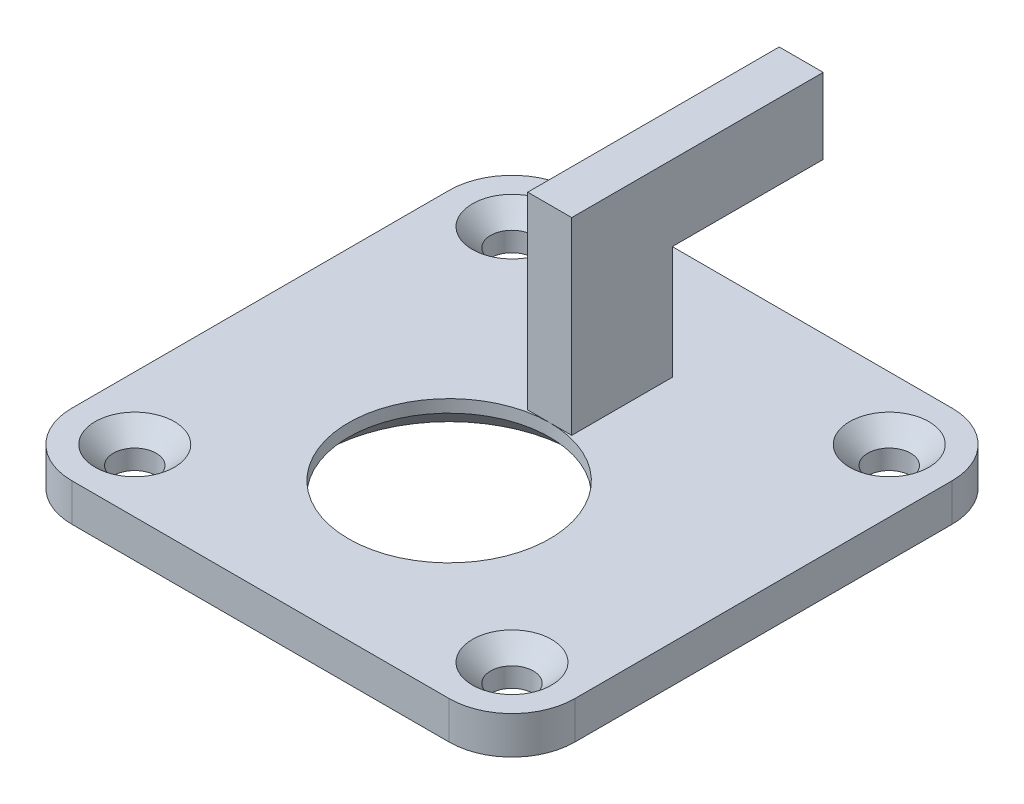
from build123d import *

# Parameters (mm, degrees)
SKETCH1_R                                    = 8
BOSS_EXTRUDE1_DEPTH                          = 3
CSK_FOR_M3_COUNTERSUNK_FLAT_HEAD_SCR_2_COUNT = 2
CSK_FOR_M3_COUNTERSUNK_FLAT_HEAD_SCR_2_PITCH = 30
CSK_FOR_M3_COUNTERSUNK_FLAT_HEAD_SCR_3_COUNT = 2
CSK_FOR_M3_COUNTERSUNK_FLAT_HEAD_SCR_3_PITCH = 42.426406871
CSK_FOR_M3_COUNTERSUNK_FLAT_HEAD_SCR_4_COUNT = 2
CSK_FOR_M3_COUNTERSUNK_FLAT_HEAD_SCR_4_PITCH = 30
CHAMFER1_SIZE                                = 2
BOSS_EXTRUDE2_DEPTH                          = 1.75


with BuildPart() as part:
    # Sketch1 → Boss-Extrude1 (new body)
    with BuildSketch(Plane(origin=(0, 0, 0), x_dir=(1, 0, 0), z_dir=(0, 1, 0))):
        with BuildLine():
            Line((-15, -15), (15, -15))
            ThreePointArc((15, -15), (18.535533906, -13.535533906), (20, -10))
            Line((20, -10), (20, 20))
            ThreePointArc((20, 20), (18.535533906, 23.535533906), (15, 25))
            Line((15, 25), (-15, 25))
            ThreePointArc((-15, 25), (-18.535533906, 23.535533906), (-20, 20))
            Line((-20, 20), (-20, -10))
            ThreePointArc((-20, -10), (-18.535533906, -13.535533906), (-15, -15))
        make_face()
        Circle(SKETCH1_R, mode=Mode.SUBTRACT)
    extrude(amount=-BOSS_EXTRUDE1_DEPTH)

    # Sketch6 → CSK for M3 Countersunk Flat Head Screw1 (revolve, cut)
    with BuildSketch(Plane(origin=(-15, 0, -20), x_dir=(0, 0, 1), z_dir=(1, 0, 0))):
        Polygon((0, 0), (0, 3), (1.7, 3), (1.7, 1.45), (3.15, 0), align=None)
    csk_for_m3_countersunk_flat_head_screw1 = revolve(axis=Axis((-15, 6.35, -20), (0, -1, 0)), mode=Mode.SUBTRACT)

    # CSK for M3 Countersunk Flat Head Scr 2: CSK for M3 Countersunk Flat Head Screw1 ×2
    with Locations(*[(i * CSK_FOR_M3_COUNTERSUNK_FLAT_HEAD_SCR_2_PITCH, 0, 0) for i in range(1, CSK_FOR_M3_COUNTERSUNK_FLAT_HEAD_SCR_2_COUNT)]):
        add(csk_for_m3_countersunk_flat_head_screw1, mode=Mode.SUBTRACT)

    # CSK for M3 Countersunk Flat Head Scr 3: CSK for M3 Countersunk Flat Head Screw1 ×2
    with Locations(*[Vector(0.707106781, 0, 0.707106781) * (i * CSK_FOR_M3_COUNTERSUNK_FLAT_HEAD_SCR_3_PITCH) for i in range(1, CSK_FOR_M3_COUNTERSUNK_FLAT_HEAD_SCR_3_COUNT)]):
        add(csk_for_m3_countersunk_flat_head_screw1, mode=Mode.SUBTRACT)

    # CSK for M3 Countersunk Flat Head Scr 4: CSK for M3 Countersunk Flat Head Screw1 ×2
    with Locations(*[(0, 0, i * CSK_FOR_M3_COUNTERSUNK_FLAT_HEAD_SCR_4_PITCH) for i in range(1, CSK_FOR_M3_COUNTERSUNK_FLAT_HEAD_SCR_4_COUNT)]):
        add(csk_for_m3_countersunk_flat_head_screw1, mode=Mode.SUBTRACT)

    # Chamfer1
    chamfer1_edges = [part.edges().sort_by_distance(p)[0] for p in [
        (-8, -3, 0),
    ]]
    chamfer(chamfer1_edges, length=CHAMFER1_SIZE)

    # Sketch9 → Boss-Extrude2 (add, symmetric)
    with BuildSketch(Plane(origin=(0, 0, 0), x_dir=(0, 0, -1), z_dir=(1, 0, 0))):
        Polygon((8, 0), (8, 15), (28, 15), (28, 9), (16, 9), (16, 0), align=None)
    extrude(amount=BOSS_EXTRUDE2_DEPTH, both=True)


solid = part.part
